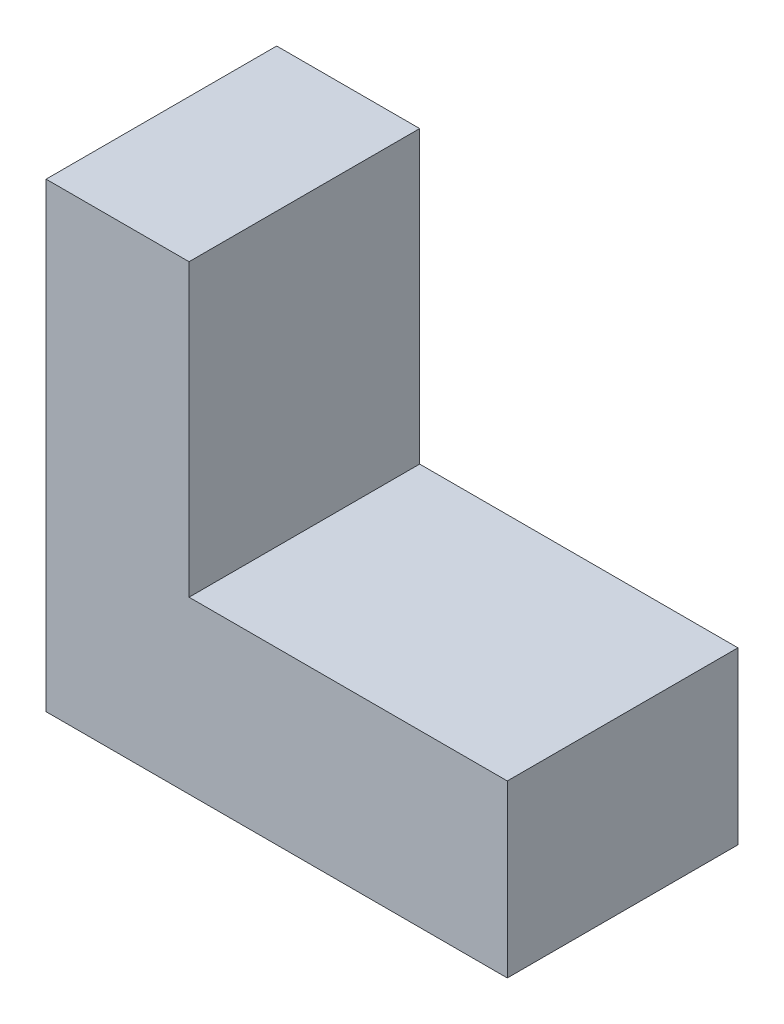
from build123d import *

# Parameters (mm, degrees)
SKETCH1_W           = 50
SKETCH1_H           = 18.5
BOSS_EXTRUDE1_DEPTH = 25
SKETCH2_W           = 15.5
SKETCH2_H           = 25
BOSS_EXTRUDE2_DEPTH = 50


with BuildPart() as part:
    # Sketch1 → Boss-Extrude1 (new body)
    with BuildSketch(Plane.XY):
        with Locations((25, 9.25)):
            Rectangle(SKETCH1_W, SKETCH1_H)
    extrude(amount=BOSS_EXTRUDE1_DEPTH)

    # Sketch2 → Boss-Extrude2 (add)
    with BuildSketch(Plane.XZ):
        with Locations((7.75, 12.5)):
            Rectangle(SKETCH2_W, SKETCH2_H)
    extrude(amount=-BOSS_EXTRUDE2_DEPTH)


solid = part.part
